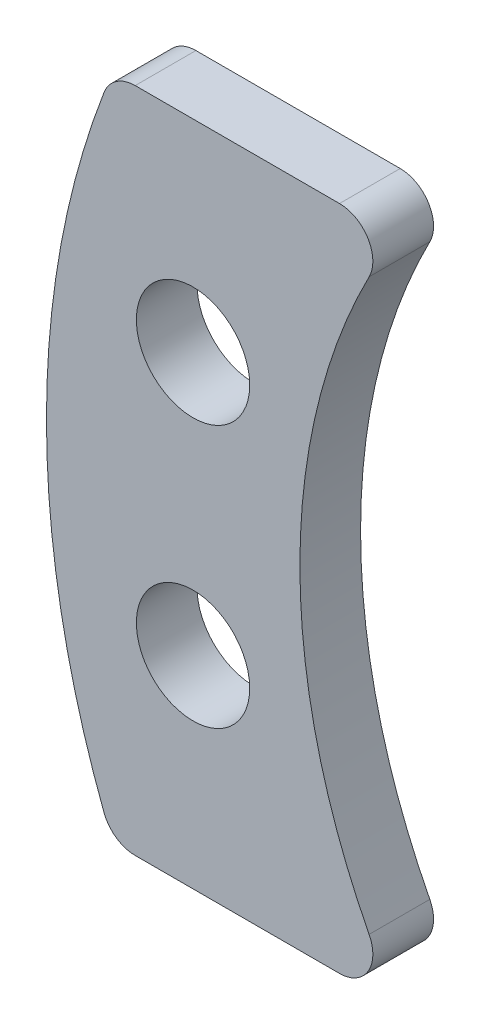
from build123d import *

# Parameters (mm, degrees)
SKETCH1_R           = 2.15900001
BOSS_EXTRUDE1_DEPTH = 2.3114
FILLET2_R           = 1.27


with BuildPart() as part:
    # Sketch1 → Boss-Extrude1 (new body)
    with BuildSketch(Plane.XY):
        with BuildLine():
            Line((12.070207479, 25.399999934), (1.230583588, 25.399999934))
            ThreePointArc((1.230583588, 25.399999934), (-1.28826593, 12.699999967), (1.230583588, 0))
            Line((1.230583588, 0), (12.070207479, 0))
            ThreePointArc((12.070207479, 0), (8.365759658, 12.699999967), (12.070207479, 25.399999934))
        make_face()
        with Locations((4.295000046, 17.7)):
            Circle(SKETCH1_R, mode=Mode.SUBTRACT)
        with Locations((4.295000046, 7.699999934)):
            Circle(SKETCH1_R, mode=Mode.SUBTRACT)
    extrude(amount=BOSS_EXTRUDE1_DEPTH)

    # Fillet2
    fillet2_edges = [part.edges().sort_by_distance(p)[0] for p in [
        (1.230583588, 25.399999934, 1.1557),
        (12.070207479, 25.399999934, 1.1557),
        (12.070207479, 0, 1.1557),
        (1.230583588, 0, 1.1557),
    ]]
    fillet(fillet2_edges, radius=FILLET2_R)


solid = part.part
